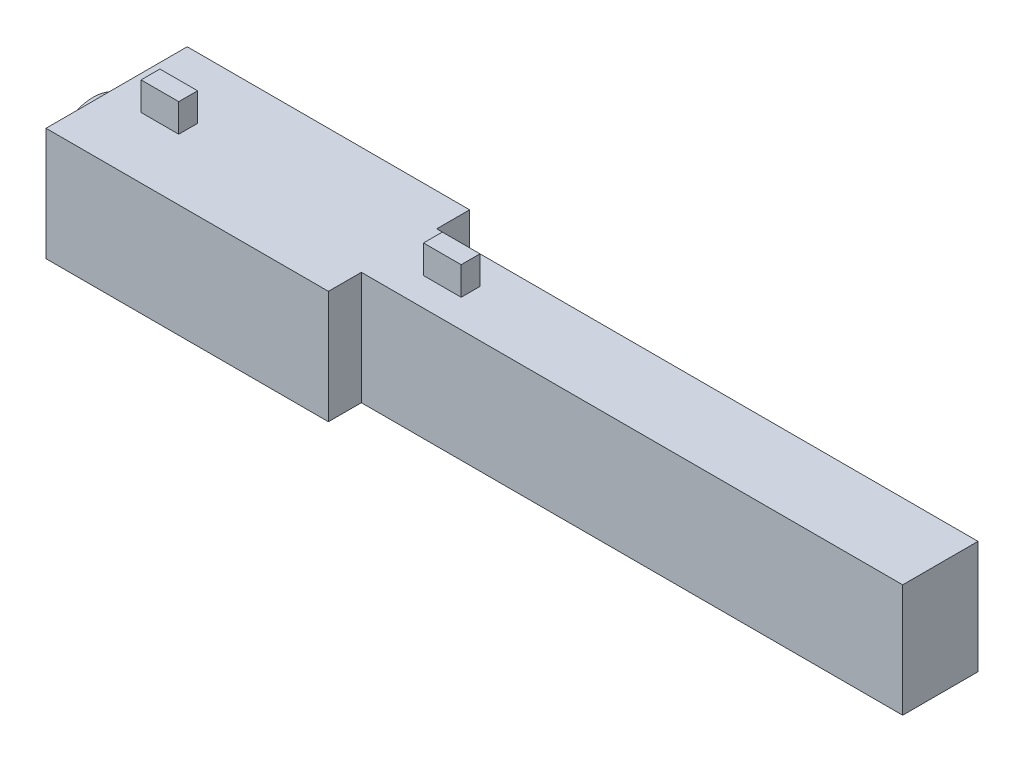
from build123d import *

# Parameters (mm, degrees)
RESSALTO_EXTRUS_O1_DEPTH      = 7.5
RESSALTO_EXTRUS_O1_DEPTH_BACK = 7.5
ESBO_O1_W                     = 30
ESBO_O1_H                     = 12
RESSALTO_EXTRUS_O2_DEPTH      = 4
RESSALTO_EXTRUS_O2_DEPTH_BACK = 4
ESBO_O1_3_W                   = 57.5
ESBO_O1_3_H                   = 12
RESSALTO_EXTRUS_O3_DEPTH      = 3
RESSALTO_EXTRUS_O4_DEPTH      = 3
RESSALTO_EXTRUS_O6_DEPTH      = 7.5
RESSALTO_EXTRUS_O6_DEPTH_BACK = 7.5
ESBO_O1_9_W                   = 30
ESBO_O1_9_H                   = 12
ESBO_O5_R                     = 2.75
CORTE_EXTRUS_O1_DEPTH         = 72
RESSALTO_EXTRUS_O7_START      = 2.5
ESBO_O5_8_R                   = 4.5
ESBO_O5_8_R_2                 = 2.75
RESSALTO_EXTRUS_O7_DEPTH      = 2.5


with BuildPart() as part:
    # Esboço1 → Ressalto-extrusão1 (new, two sides: drawn at the far end of the back side and taken through both)
    with BuildSketch(Plane.XY.offset(-RESSALTO_EXTRUS_O1_DEPTH_BACK)):
        with Locations((-40.5, -0.65)):
            Rectangle(ESBO_O1_W, ESBO_O1_H)
    extrude(amount=RESSALTO_EXTRUS_O1_DEPTH + RESSALTO_EXTRUS_O1_DEPTH_BACK)

    # Esboço1<3> → Ressalto-extrusão2 (add, two sides: drawn at the far end of the back side and taken through both)
    with BuildSketch(Plane.XY.offset(-RESSALTO_EXTRUS_O2_DEPTH_BACK)):
        with Locations((3.25, -0.65)):
            Rectangle(ESBO_O1_3_W, ESBO_O1_3_H)
    extrude(amount=RESSALTO_EXTRUS_O2_DEPTH + RESSALTO_EXTRUS_O2_DEPTH_BACK)

    # Esboço2 → Ressalto-extrusão3 (add)
    with BuildSketch(Plane(origin=(-55.5, -6.65, -7.5), x_dir=(-1, 0, 0), z_dir=(0, -1, 0))):
        Polygon((-37.6, -6.5), (-37.6, -7.5), (-37.6, -8.5), (-33.6, -8.5), (-33.6, -6.5), align=None)
        Polygon((-7.6, -7.5), (-7.6, -8.5), (-3.6, -8.5), (-3.6, -7.5), (-3.6, -6.5), (-7.6, -6.5), align=None)
    extrude(amount=RESSALTO_EXTRUS_O3_DEPTH)

    # Esboço3 → Ressalto-extrusão4 (add)
    with BuildSketch(Plane(origin=(-55.5, 5.35, -7.5), x_dir=(-1, 0, 0), z_dir=(0, -1, 0))):
        Polygon((-37.6, -6.5), (-37.6, -7.5), (-37.6, -8.5), (-33.6, -8.5), (-33.6, -6.5), align=None)
        Polygon((-7.6, -7.5), (-7.6, -8.5), (-3.6, -8.5), (-3.6, -7.5), (-3.6, -6.5), (-7.6, -6.5), align=None)
    extrude(amount=-RESSALTO_EXTRUS_O4_DEPTH)

    # Esboço1<9> → Ressalto-extrusão6 (add, two sides: drawn at the far end of the back side and taken through both)
    with BuildSketch(Plane.XY.offset(-RESSALTO_EXTRUS_O6_DEPTH_BACK)):
        with Locations((-40.5, -0.65)):
            Rectangle(ESBO_O1_9_W, ESBO_O1_9_H)
    extrude(amount=RESSALTO_EXTRUS_O6_DEPTH + RESSALTO_EXTRUS_O6_DEPTH_BACK)

    # Esboço5 → Corte-extrusão1 (cut)
    with BuildSketch(Plane(origin=(-55.5, 5.35, -7.5), x_dir=(0, 0, 1), z_dir=(-1, 0, 0))):
        with Locations((7.5, -6.65)):
            Circle(ESBO_O5_R)
    extrude(amount=-CORTE_EXTRUS_O1_DEPTH, mode=Mode.SUBTRACT)

    # Esboço5<8> → Ressalto-extrusão7 (add)
    with BuildSketch(Plane(origin=(-55.5, 5.35, -7.5), x_dir=(0, 0, 1), z_dir=(-1, 0, 0)).offset(RESSALTO_EXTRUS_O7_START)):
        with Locations((7.5, -6.65)):
            Circle(ESBO_O5_8_R)
        with Locations((7.5, -6.65)):
            Circle(ESBO_O5_8_R_2, mode=Mode.SUBTRACT)
    extrude(amount=-RESSALTO_EXTRUS_O7_DEPTH)


solid = part.part
